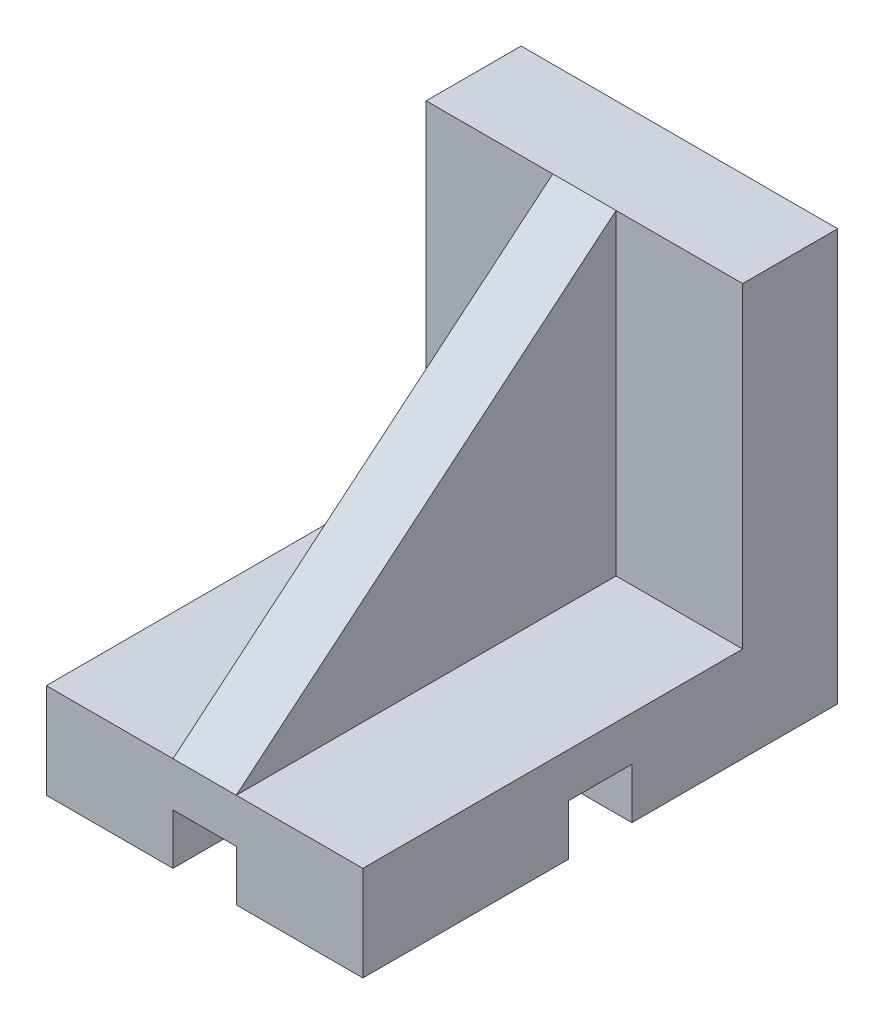
from build123d import *

# Parameters (mm, degrees)
IZIM1_W                     = 50
IZIM1_H                     = 75
Y_KSEKLIK_EKSTR_ZYON1_DEPTH = 15
IZIM2_W                     = 50
IZIM2_H                     = 15
Y_KSEKLIK_EKSTR_ZYON2_DEPTH = 50
Y_KSEKLIK_EKSTR_ZYON3_DEPTH = 5
IZIM5_W                     = 10
IZIM5_H                     = 8
KES_EKSTR_ZYON1_DEPTH       = 76
IZIM6_W                     = 10
IZIM6_H                     = 8
KES_EKSTR_ZYON2_DEPTH       = 51


with BuildPart() as part:
    # Çizim1 → Yükseklik-Ekstrüzyon1 (new body)
    with BuildSketch(Plane(origin=(0, 0, 0), x_dir=(1, 0, 0), z_dir=(0, 1, 0))):
        Rectangle(IZIM1_W, IZIM1_H)
    extrude(amount=Y_KSEKLIK_EKSTR_ZYON1_DEPTH)

    # Çizim2 → Yükseklik-Ekstrüzyon2 (add)
    with BuildSketch(Plane(origin=(0, 15, 0), x_dir=(1, 0, 0), z_dir=(0, 1, 0))):
        with Locations((0, 30)):
            Rectangle(IZIM2_W, IZIM2_H)
    extrude(amount=Y_KSEKLIK_EKSTR_ZYON2_DEPTH)

    # Çizim4 → Yükseklik-Ekstrüzyon3 (add, symmetric)
    with BuildSketch(Plane(origin=(0, 0, 0), x_dir=(0, 0, -1), z_dir=(1, 0, 0))):
        Polygon((22.5, 65), (-37.5, 15), (22.5, 15), align=None)
    extrude(amount=Y_KSEKLIK_EKSTR_ZYON3_DEPTH, both=True)

    # Çizim5 → Kes-Ekstrüzyon1 (cut, through all)
    with BuildSketch(Plane.XY.offset(37.5)):
        with Locations((0, 4)):
            Rectangle(IZIM5_W, IZIM5_H)
    extrude(amount=-KES_EKSTR_ZYON1_DEPTH, mode=Mode.SUBTRACT)

    # Çizim6 → Kes-Ekstrüzyon2 (cut, through all)
    with BuildSketch(Plane(origin=(25, 0, 0), x_dir=(0, 0, -1), z_dir=(1, 0, 0))):
        with Locations((0, 4)):
            Rectangle(IZIM6_W, IZIM6_H)
    extrude(amount=-KES_EKSTR_ZYON2_DEPTH, mode=Mode.SUBTRACT)


solid = part.part
